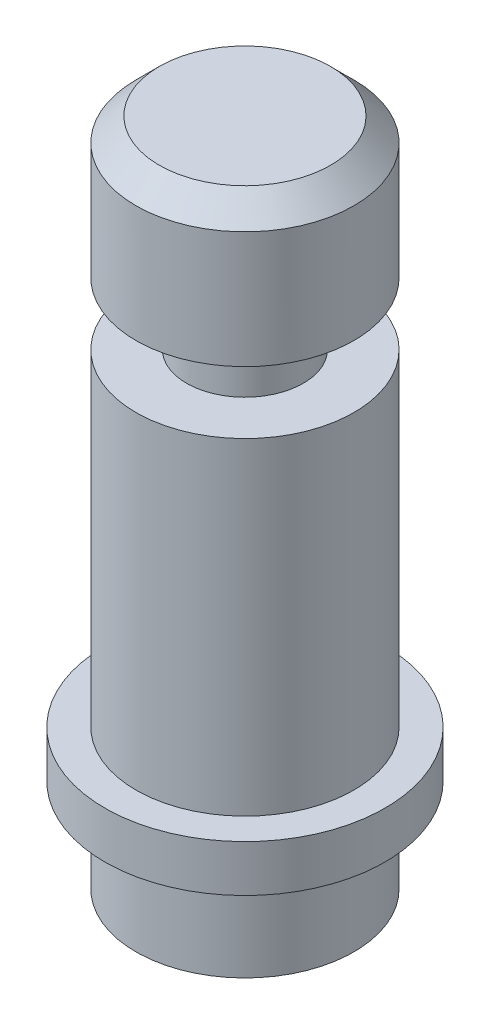
from build123d import *

# Parameters (mm, degrees)
CHAMFER1_SIZE = 1.5


with BuildPart() as part:
    # Sketch1 → Revolve1 (revolve)
    with BuildSketch(Plane.XY):
        Polygon((7, 0), (0, 0), (0, 6), (-2, 6), (-2, 9), (0, 9), (0, 30), (3.25, 30), (3.25, 34), (0, 34), (0, 43), (7, 43), align=None)
    revolve(axis=Axis((7, 43, 0), (0, -1, 0)))

    # Chamfer1
    chamfer1_edges = [part.edges().sort_by_distance(p)[0] for p in [
        (14, 43, 0),
    ]]
    chamfer(chamfer1_edges, length=CHAMFER1_SIZE)


solid = part.part
